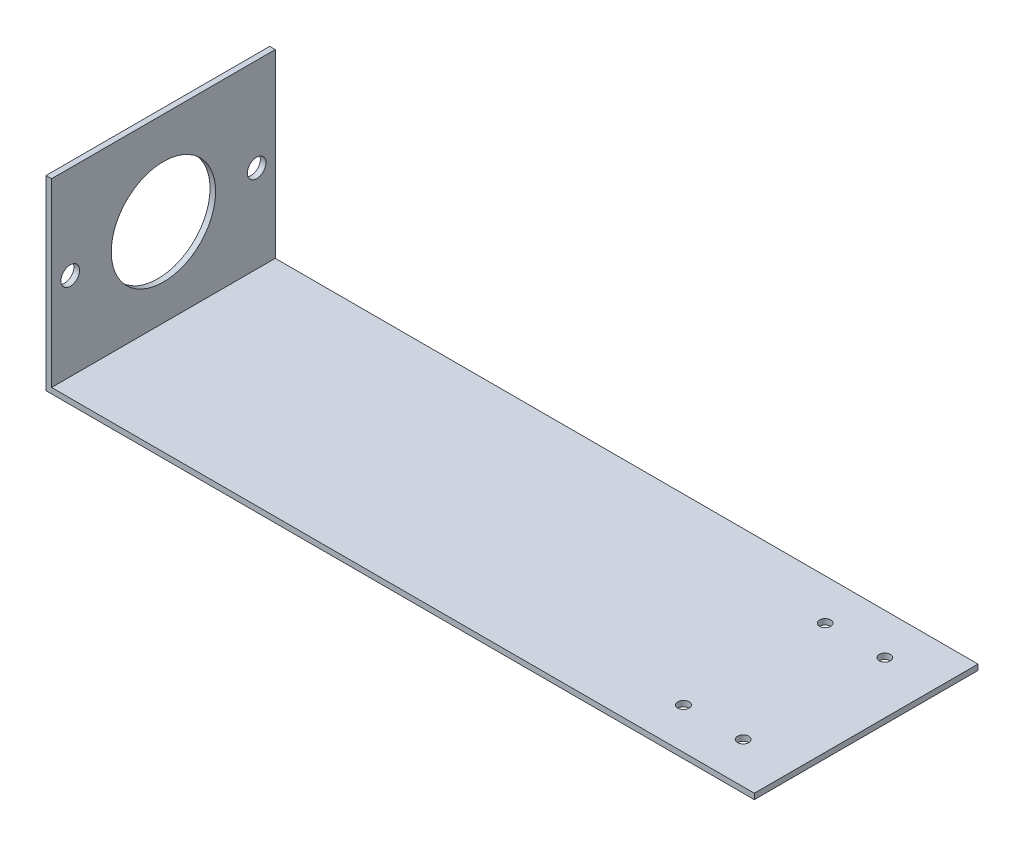
from build123d import *

# Parameters (mm, degrees)
BOSS_EXTRUDE1_DEPTH = 60
CUT_EXTRUDE1_REACH  = 3.5
SKETCH2_R           = 14
SKETCH2_R_2         = 2.5
CUT_EXTRUDE2_REACH  = 3.5
SKETCH3_R           = 1.5


with BuildPart() as part:
    # Sketch1 → Boss-Extrude1 (new body)
    with BuildSketch(Plane.XY):
        Polygon((0, 0), (0, 50), (1.5, 50), (1.5, 1.5), (190, 1.5), (190, 0), align=None)
    extrude(amount=BOSS_EXTRUDE1_DEPTH)

    # Sketch2 → Cut-Extrude1 (cut, up to next)
    with BuildSketch(Plane(origin=(1.5, 0, 0), x_dir=(0, 0, -1), z_dir=(1, 0, 0)), mode=Mode.PRIVATE) as cut_extrude1_sk1:
        with Locations((-30, 25)):
            Circle(SKETCH2_R)
    cut_extrude1_tool1 = extrude(cut_extrude1_sk1.sketch, amount=-CUT_EXTRUDE1_REACH, mode=Mode.PRIVATE) & part.part
    add(cut_extrude1_tool1.solids().sort_by_distance((1.5, 25, 30))[0], mode=Mode.SUBTRACT)
    # Sketch2 → Cut-Extrude1 (cut, up to next)
    with BuildSketch(Plane(origin=(1.5, 0, 0), x_dir=(0, 0, -1), z_dir=(1, 0, 0)), mode=Mode.PRIVATE) as cut_extrude1_sk2:
        with Locations((-55, 25)):
            Circle(SKETCH2_R_2)
    cut_extrude1_tool2 = extrude(cut_extrude1_sk2.sketch, amount=-CUT_EXTRUDE1_REACH, mode=Mode.PRIVATE) & part.part
    add(cut_extrude1_tool2.solids().sort_by_distance((1.5, 25, 55))[0], mode=Mode.SUBTRACT)
    # Sketch2 → Cut-Extrude1 (cut, up to next)
    with BuildSketch(Plane(origin=(1.5, 0, 0), x_dir=(0, 0, -1), z_dir=(1, 0, 0)), mode=Mode.PRIVATE) as cut_extrude1_sk3:
        with Locations((-5, 25)):
            Circle(SKETCH2_R_2)
    cut_extrude1_tool3 = extrude(cut_extrude1_sk3.sketch, amount=-CUT_EXTRUDE1_REACH, mode=Mode.PRIVATE) & part.part
    add(cut_extrude1_tool3.solids().sort_by_distance((1.5, 25, 5))[0], mode=Mode.SUBTRACT)

    # Sketch3 → Cut-Extrude2 (cut, up to next)
    with BuildSketch(Plane(origin=(0, 1.5, 0), x_dir=(1, 0, 0), z_dir=(0, 1, 0)), mode=Mode.PRIVATE) as cut_extrude2_sk1:
        with Locations((160, -11)):
            Circle(SKETCH3_R)
    cut_extrude2_tool1 = extrude(cut_extrude2_sk1.sketch, amount=-CUT_EXTRUDE2_REACH, mode=Mode.PRIVATE) & part.part
    add(cut_extrude2_tool1.solids().sort_by_distance((160, 1.5, 11))[0], mode=Mode.SUBTRACT)
    # Sketch3 → Cut-Extrude2 (cut, up to next)
    with BuildSketch(Plane(origin=(0, 1.5, 0), x_dir=(1, 0, 0), z_dir=(0, 1, 0)), mode=Mode.PRIVATE) as cut_extrude2_sk2:
        with Locations((176, -11)):
            Circle(SKETCH3_R)
    cut_extrude2_tool2 = extrude(cut_extrude2_sk2.sketch, amount=-CUT_EXTRUDE2_REACH, mode=Mode.PRIVATE) & part.part
    add(cut_extrude2_tool2.solids().sort_by_distance((176, 1.5, 11))[0], mode=Mode.SUBTRACT)
    # Sketch3 → Cut-Extrude2 (cut, up to next)
    with BuildSketch(Plane(origin=(0, 1.5, 0), x_dir=(1, 0, 0), z_dir=(0, 1, 0)), mode=Mode.PRIVATE) as cut_extrude2_sk3:
        with Locations((176, -49)):
            Circle(SKETCH3_R)
    cut_extrude2_tool3 = extrude(cut_extrude2_sk3.sketch, amount=-CUT_EXTRUDE2_REACH, mode=Mode.PRIVATE) & part.part
    add(cut_extrude2_tool3.solids().sort_by_distance((176, 1.5, 49))[0], mode=Mode.SUBTRACT)
    # Sketch3 → Cut-Extrude2 (cut, up to next)
    with BuildSketch(Plane(origin=(0, 1.5, 0), x_dir=(1, 0, 0), z_dir=(0, 1, 0)), mode=Mode.PRIVATE) as cut_extrude2_sk4:
        with Locations((160, -49)):
            Circle(SKETCH3_R)
    cut_extrude2_tool4 = extrude(cut_extrude2_sk4.sketch, amount=-CUT_EXTRUDE2_REACH, mode=Mode.PRIVATE) & part.part
    add(cut_extrude2_tool4.solids().sort_by_distance((160, 1.5, 49))[0], mode=Mode.SUBTRACT)


solid = part.part
